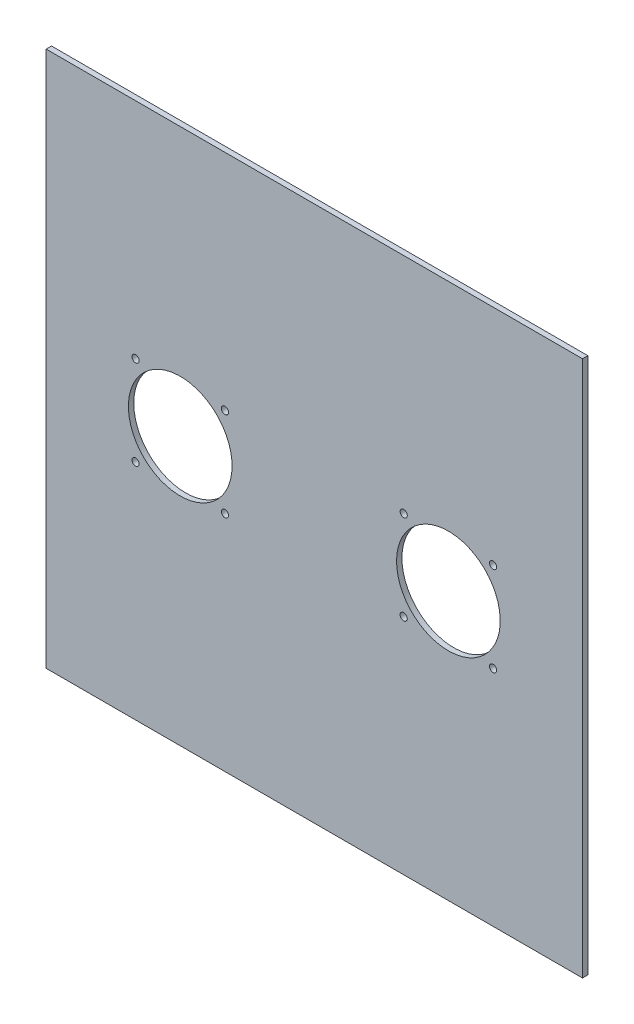
from build123d import *

# Parameters (mm, degrees)
CROQUIS1_W              = 300
CROQUIS1_H              = 300
SALIENTE_EXTRUIR1_DEPTH = 3
CROQUIS2_R              = 2
CROQUIS2_R_2            = 29
CORTAR_EXTRUIR1_DEPTH   = 10


with BuildPart() as part:
    # Croquis1 → Saliente-Extruir1 (new body)
    with BuildSketch(Plane.XY):
        with Locations((150, 150)):
            Rectangle(CROQUIS1_W, CROQUIS1_H)
    extrude(amount=SALIENTE_EXTRUIR1_DEPTH)

    # Croquis2 → Cortar-Extruir1 (cut)
    with BuildSketch(Plane.XY.offset(3)):
        with Locations((50, 175)):
            Circle(CROQUIS2_R)
        with Locations((100, 175)):
            Circle(CROQUIS2_R)
        with Locations((100, 125)):
            Circle(CROQUIS2_R)
        with Locations((50, 125)):
            Circle(CROQUIS2_R)
        with Locations((75, 150)):
            Circle(CROQUIS2_R_2)
        with Locations((200, 125)):
            Circle(CROQUIS2_R)
        with Locations((250, 125)):
            Circle(CROQUIS2_R)
        with Locations((200, 175)):
            Circle(CROQUIS2_R)
        with Locations((225, 150)):
            Circle(CROQUIS2_R_2)
        with Locations((250, 175)):
            Circle(CROQUIS2_R)
    extrude(amount=-CORTAR_EXTRUIR1_DEPTH, mode=Mode.SUBTRACT)


solid = part.part
